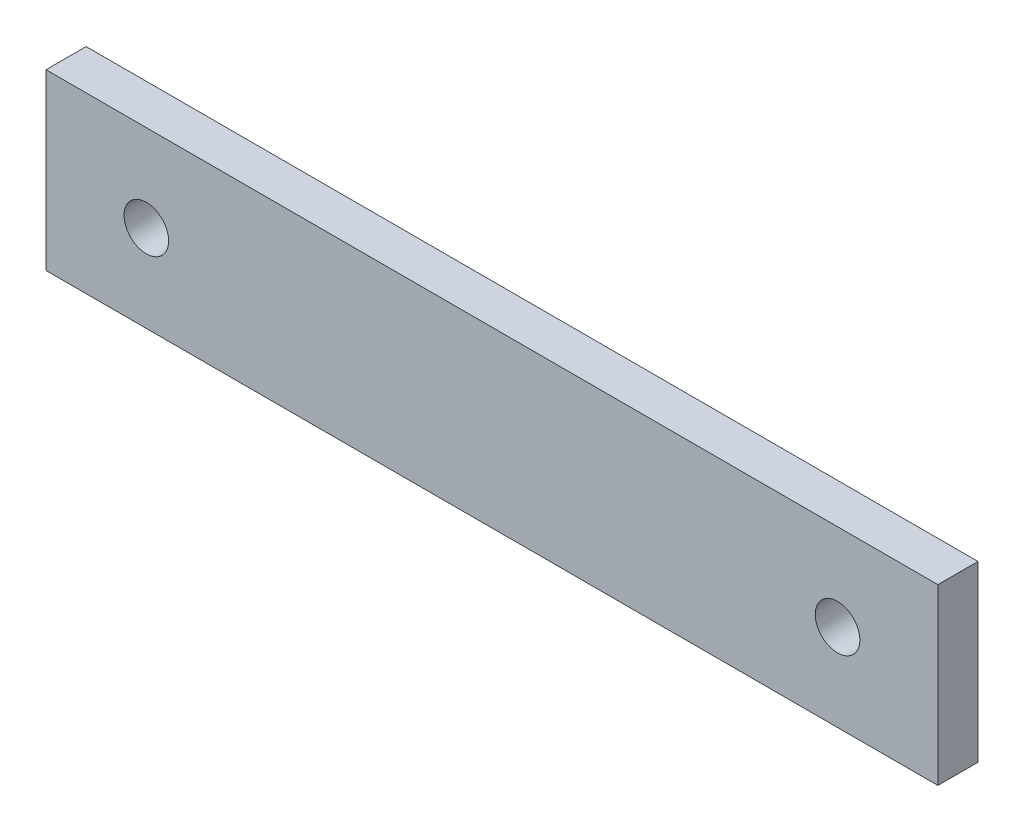
from build123d import *

# Parameters (mm, degrees)
ESQUISSE1_W        = 200
ESQUISSE1_H        = 39
ESQUISSE1_R        = 5
BOSS_EXTRU_1_DEPTH = 9


with BuildPart() as part:
    # Esquisse1 → Boss.-Extru.1 (new body)
    with BuildSketch(Plane.XY):
        with Locations((56.894736842, -1.368421053)):
            Rectangle(ESQUISSE1_W, ESQUISSE1_H)
        with Locations((-20.605263158, -1.368421053)):
            Circle(ESQUISSE1_R, mode=Mode.SUBTRACT)
        with Locations((134.394736842, -1.368421053)):
            Circle(ESQUISSE1_R, mode=Mode.SUBTRACT)
    extrude(amount=BOSS_EXTRU_1_DEPTH)


solid = part.part
